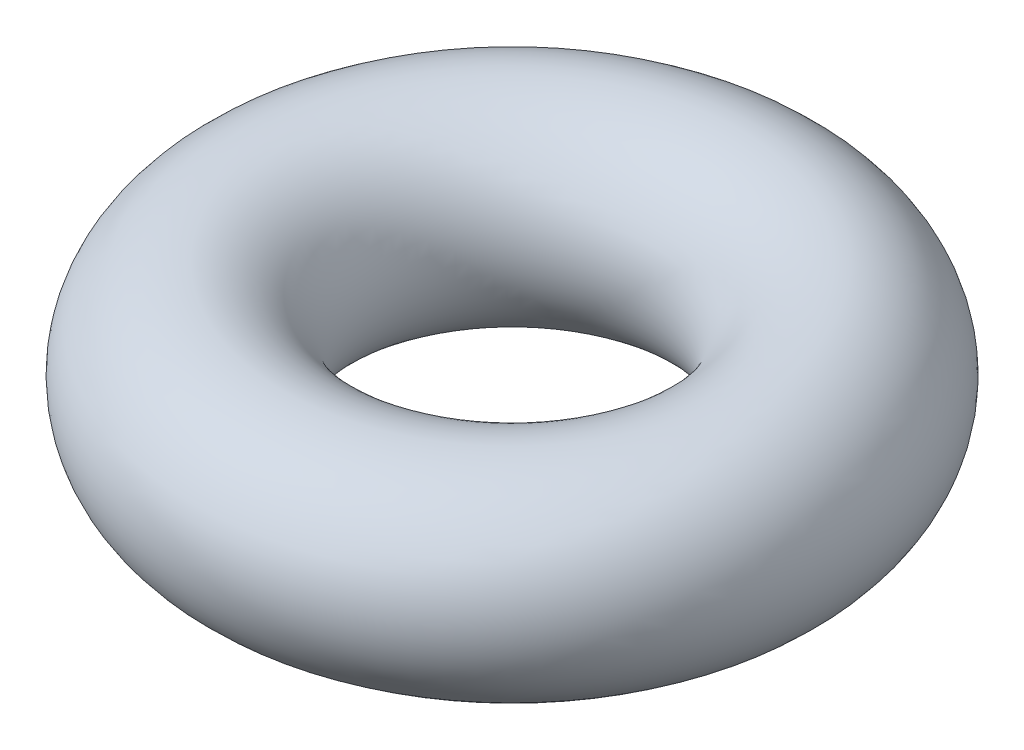
from build123d import *

# Parameters (mm, degrees)
SKETCH1_R = 1.016


with BuildPart() as part:
    # Sketch1 → Revolve1 (revolve)
    with BuildSketch(Plane.XY):
        with Locations((2.3622, 0)):
            Circle(SKETCH1_R)
    revolve(axis=Axis((0, 1.691755682, 0), (0, -1, 0)))


solid = part.part
